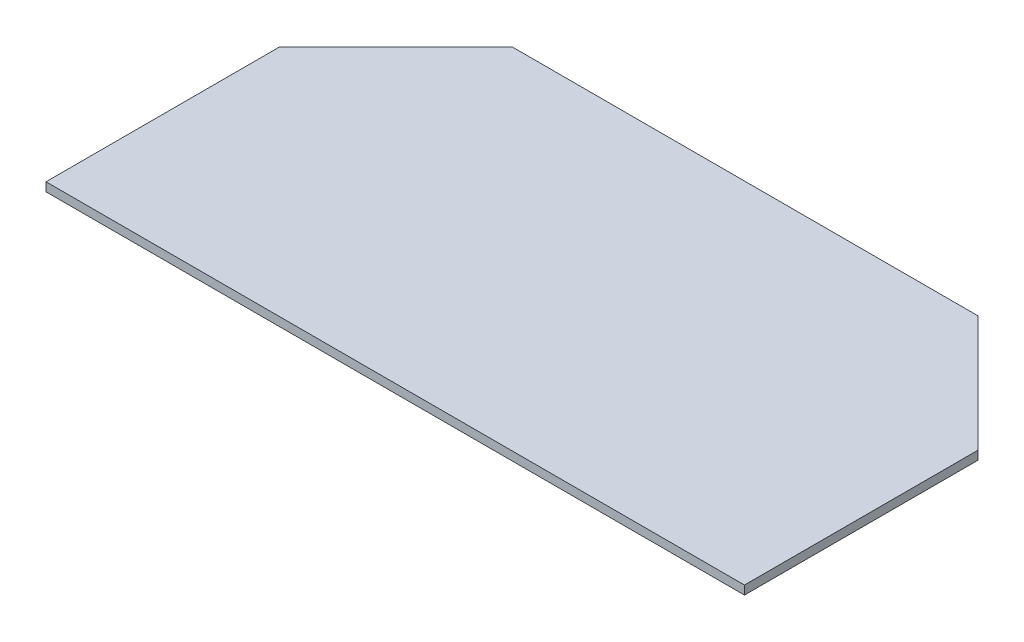
from build123d import *

# Parameters (mm, degrees)
BOSS_EXTRUDE1_DEPTH = 1


with BuildPart() as part:
    # Sketch1 → Boss-Extrude1 (new body)
    with BuildSketch(Plane(origin=(0, 0, 0), x_dir=(1, 0, 0), z_dir=(0, 1, 0))):
        Polygon((-39.692127922, 30.316864608), (13.757872078, 30.316864608), (27.107872078, 16.966864608), (27.107872078, -9.833135392), (-53.042127922, -9.833135392), (-53.042127922, 16.966864608), align=None)
    extrude(amount=BOSS_EXTRUDE1_DEPTH)


solid = part.part
